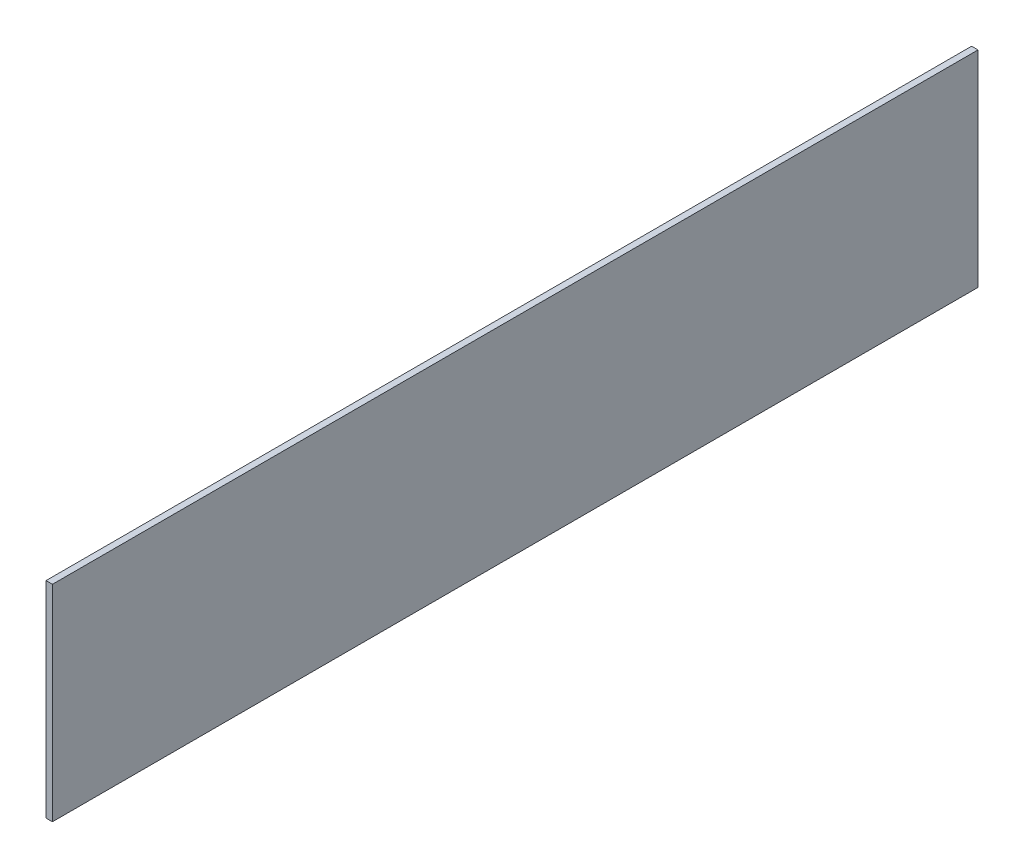
from build123d import *

# Parameters (mm, degrees)
SKETCH1_W           = 228.6
SKETCH1_H           = 50.8
BOSS_EXTRUDE1_DEPTH = 0.79375


with BuildPart() as part:
    # Sketch1 → Boss-Extrude1 (new body, symmetric)
    with BuildSketch(Plane(origin=(0, 0, 0), x_dir=(0, 0, -1), z_dir=(1, 0, 0))):
        Rectangle(SKETCH1_W, SKETCH1_H)
    extrude(amount=BOSS_EXTRUDE1_DEPTH, both=True)


solid = part.part
